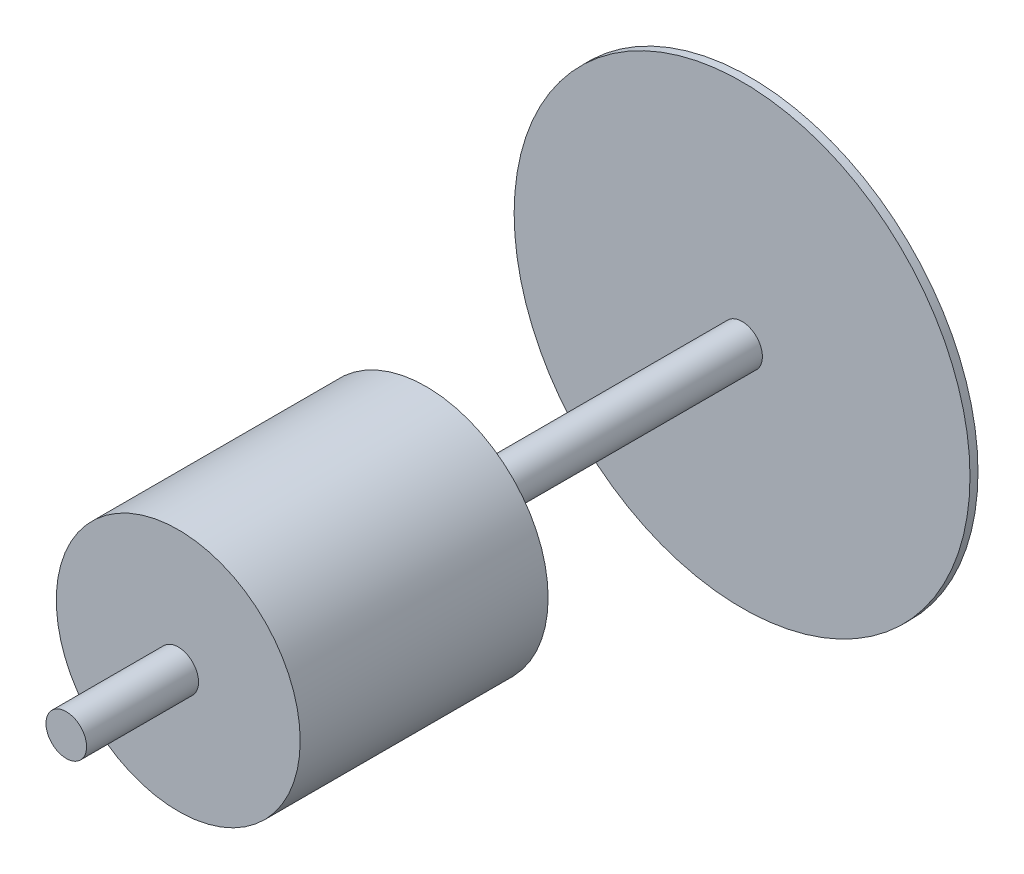
from build123d import *

# Parameters (mm, degrees)
SKETCH1_R                = 50.8
BOSS_EXTRUDE1_DEPTH      = 1030
BOSS_EXTRUDE1_DEPTH_BACK = 680
SKETCH2_R                = 570
BOSS_EXTRUDE2_DEPTH      = 20
BOSS_EXTRUDE3_START      = -280
SKETCH7_R                = 305
BOSS_EXTRUDE3_DEPTH      = 620
SKETCH8_R                = 225
BOSS_EXTRUDE4_DEPTH      = 50


with BuildPart() as part:
    # Sketch1 → Boss-Extrude1 (new body, two sides)
    with BuildSketch(Plane.XY) as boss_extrude1_sk:
        Circle(SKETCH1_R)
    extrude(amount=BOSS_EXTRUDE1_DEPTH)
    extrude(boss_extrude1_sk.sketch, amount=-BOSS_EXTRUDE1_DEPTH_BACK)

    # Sketch2 → Boss-Extrude2 (add)
    with BuildSketch(Plane.XY.offset(-680)):
        Circle(SKETCH2_R)
    extrude(amount=BOSS_EXTRUDE2_DEPTH)

    # Sketch7 → Boss-Extrude3 (add)
    with BuildSketch(Plane.XY.offset(1030).offset(BOSS_EXTRUDE3_START)):
        Circle(SKETCH7_R)
    extrude(amount=-BOSS_EXTRUDE3_DEPTH)

    # Sketch8 → Boss-Extrude4 (add)
    with BuildSketch(Plane(origin=(0, 0, 130), x_dir=(-1, 0, 0), z_dir=(0, 0, -1))):
        Circle(SKETCH8_R)
    extrude(amount=BOSS_EXTRUDE4_DEPTH)


solid = part.part
